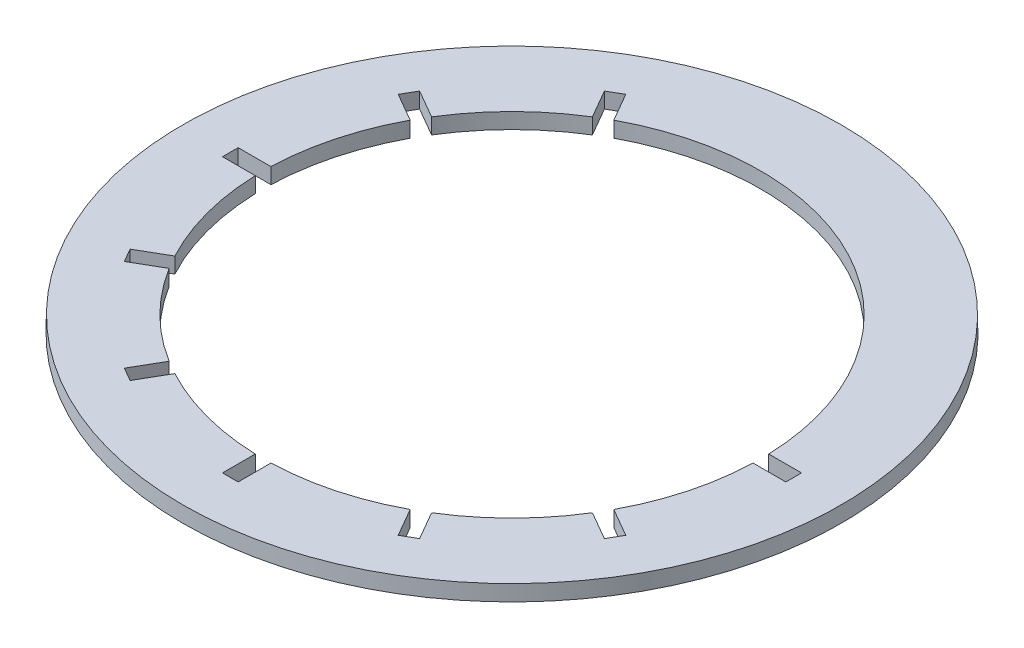
from build123d import *

# Parameters (mm, degrees)
SKETCH1_R           = 105.177936238
SKETCH1_R_2         = 79.476526286
BOSS_EXTRUDE1_DEPTH = 5
SKETCH3_W           = 25.87147266
SKETCH3_H           = 5
CUT_EXTRUDE1_DEPTH  = 5
CIRPATTERN1_COUNT   = 9
CIRPATTERN1_ANGLE   = 240


with BuildPart() as part:
    # Sketch1 → Boss-Extrude1 (new body)
    with BuildSketch(Plane(origin=(0, 0, 0), x_dir=(1, 0, 0), z_dir=(0, 1, 0))):
        Circle(SKETCH1_R)
        Circle(SKETCH1_R_2, mode=Mode.SUBTRACT)
    extrude(amount=BOSS_EXTRUDE1_DEPTH)

    # Sketch2 → Cut-Revolve1 (revolve, cut)
    with BuildSketch(Plane.XY):
        Polygon((105.177936238, 0), (105.037977295, 6.300404607), (110.743312601, 6.300404607), (110.743312601, 0), align=None)
    revolve(axis=Axis((0, 0, 0), (0, 1, 0)), mode=Mode.SUBTRACT)

    # Sketch3 → Cut-Extrude1 (cut)
    with BuildSketch(Plane(origin=(0, 5, 0), x_dir=(1, 0, 0), z_dir=(0, 1, 0))):
        with Locations((76.959203751, 0)):
            Rectangle(SKETCH3_W, SKETCH3_H)
    cut_extrude1 = extrude(amount=-CUT_EXTRUDE1_DEPTH, mode=Mode.SUBTRACT)

    # CirPattern1: Cut-Extrude1 ×9 about axis
    cirpattern1_axis = Axis((0, 0, 0), (0, -1, 0))
    for i in range(1, CIRPATTERN1_COUNT):
        add(cut_extrude1.rotate(cirpattern1_axis, i * CIRPATTERN1_ANGLE / (CIRPATTERN1_COUNT - 1)), mode=Mode.SUBTRACT)


solid = part.part
